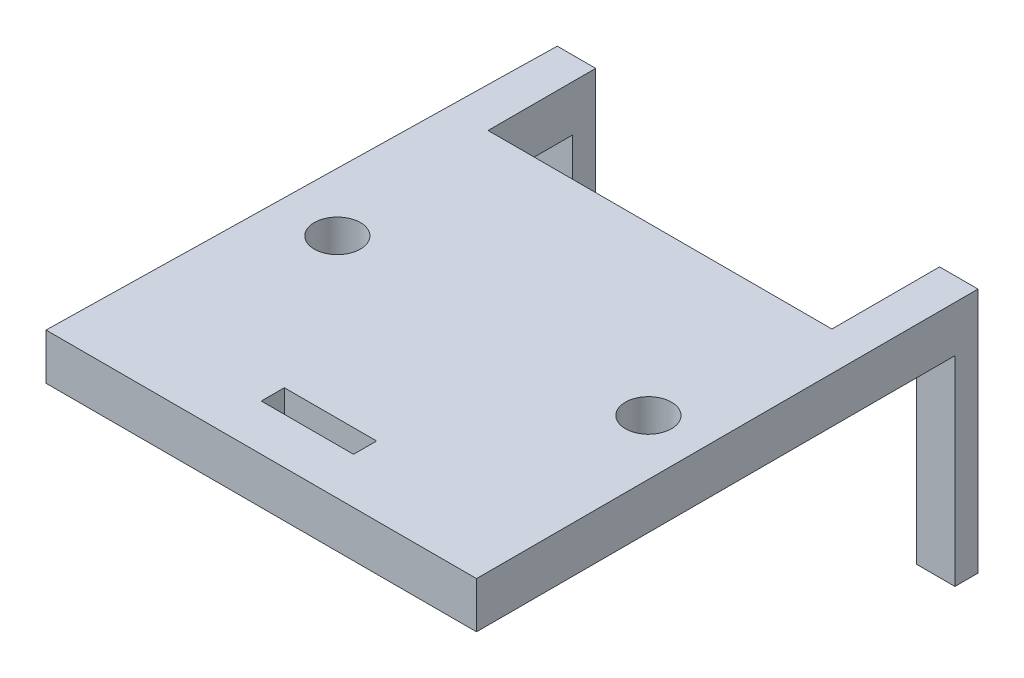
from build123d import *

# Parameters (mm, degrees)
BOSS_EXTRUDE1_DEPTH = 3
BOSS_EXTRUDE2_DEPTH = 13
SKETCH4_W           = 2.5
SKETCH4_H           = 1.5
BOSS_EXTRUDE3_DEPTH = 13
SKETCH5_R           = 1.5
CUT_EXTRUDE2_DEPTH  = 10
SKETCH6_W           = 6
SKETCH6_H           = 1.5
CUT_EXTRUDE3_DEPTH  = 10


with BuildPart() as part:
    # Sketch1 → Boss-Extrude1 (new body)
    with BuildSketch(Plane(origin=(0, 0, 0), x_dir=(1, 0, 0), z_dir=(0, 1, 0))):
        Polygon((2.636620285, -0.001333349), (24.999999567, -0.001333349), (24.999999567, 6.998666651), (27.499999567, 6.998666651), (27.499999567, 0.004879765), (27.499999567, -25.613592849), (-0.500000433, -25.613592849), (0, 0), (0.136620285, 6.998666651), (2.636620285, 6.998666651), align=None)
    extrude(amount=BOSS_EXTRUDE1_DEPTH)

    # Sketch2 → Boss-Extrude2 (add)
    with BuildSketch(Plane(origin=(0, 0, 0), x_dir=(-1, 0, 0), z_dir=(0, -1, 0))):
        Polygon((-2.636620285, 6.998666651), (-0.136620285, 6.998666651), (-0.107338932, 5.498666651), (-2.636620285, 5.498666651), align=None)
    extrude(amount=BOSS_EXTRUDE2_DEPTH)

    # Sketch4 → Boss-Extrude3 (add)
    with BuildSketch(Plane(origin=(0, 0, 0), x_dir=(-1, 0, 0), z_dir=(0, -1, 0))):
        with Locations((-26.249999567, 6.248666651)):
            Rectangle(SKETCH4_W, SKETCH4_H)
    extrude(amount=BOSS_EXTRUDE3_DEPTH)

    # Sketch5 → Cut-Extrude2 (cut)
    with BuildSketch(Plane(origin=(0, 3, 0), x_dir=(1, 0, 0), z_dir=(0, 1, 0))):
        with Locations((3.669128533, -10.836145103)):
            Circle(SKETCH5_R)
        with Locations((23.902624268, -10.836145103)):
            Circle(SKETCH5_R)
    extrude(amount=-CUT_EXTRUDE2_DEPTH, mode=Mode.SUBTRACT)

    # Sketch6 → Cut-Extrude3 (cut)
    with BuildSketch(Plane(origin=(0, 3, 0), x_dir=(1, 0, 0), z_dir=(0, 1, 0))):
        with Locations((13.499999567, -21.863592849)):
            Rectangle(SKETCH6_W, SKETCH6_H)
    extrude(amount=-CUT_EXTRUDE3_DEPTH, mode=Mode.SUBTRACT)


solid = part.part
